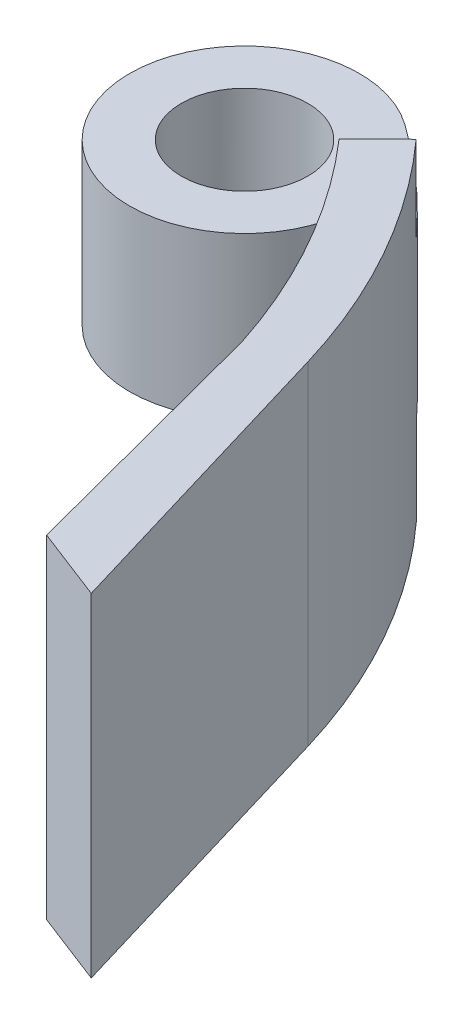
from build123d import *

# Parameters (mm, degrees)
SKETCH2_R                = 5.5
BOSS_EXTRUDE1_DEPTH      = 29
SKETCH3_R                = 12
CUT_EXTRUDE5_DEPTH       = 7
CUT_EXTRUDE5_DEPTH_BACK  = 0.5
SKETCH6_R                = 12
CUT_EXTRUDE6_DEPTH       = 7
CUT_EXTRUDE6_DEPTH_BACK  = 0.5
SKETCH9_R                = 4
SKETCH9_R_2              = 2
BOSS_EXTRUDE2_DEPTH      = 1
BOSS_EXTRUDE2_DEPTH_BACK = 1


with BuildPart() as part:
    # Sketch2 → Boss-Extrude1 (new body)
    with BuildSketch(Plane(origin=(0, 0, 0), x_dir=(1, 0, 0), z_dir=(0, 1, 0))):
        with BuildLine():
            ThreePointArc((50.009794046, 41.311227393), (41.887297641, 57.884223181), (28.818508763, 70.916716976))
            ThreePointArc((28.818508763, 70.916716976), (13.814285335, 58.864855467), (32.908133208, 61.2729792))
            ThreePointArc((32.908133208, 61.2729792), (40.45496434, 51.34849017), (45.618872448, 40.00017771))
            Line((45.618872448, 40.00017771), (51.710808427, 16.848599978))
            Line((51.710808427, 16.848599978), (58.045348615, 14.398829975))
            Line((58.045348615, 14.398829975), (50.009794046, 41.311227393))
        make_face()
        with Locations((23.020672213, 62.769012309)):
            Circle(SKETCH2_R, mode=Mode.SUBTRACT)
    extrude(amount=BOSS_EXTRUDE1_DEPTH)

    # Sketch3 → Cut-Extrude5 (cut, two sides)
    with BuildSketch(Plane(origin=(0, 7, 0), x_dir=(-1, 0, 0), z_dir=(0, -1, 0))) as cut_extrude5_sk:
        Polygon((-39.457331724, 64.63900974), (-16.53662743, 40.953334568), (-1.019451578, 59.252301049), (-23.940155872, 82.937976221), align=None)
        with Locations((-23.020672213, 62.769012309)):
            Circle(SKETCH3_R, mode=Mode.SUBTRACT)
        with BuildLine():
            ThreePointArc((-11.020672213, 62.769012309), (-24.609375035, 74.663381706), (-34.600009437, 59.619575938))
            Line((-34.600009437, 59.619575938), (-26.548423191, 51.29927068))
            ThreePointArc((-26.548423191, 51.29927068), (-15.890911057, 53.116732482), (-11.020672213, 62.769012309))
        make_face()
        with BuildLine():
            Line((-26.548423191, 51.29927068), (-34.600009437, 59.619575938))
            ThreePointArc((-34.600009437, 59.619575938), (-31.644064723, 54.424127551), (-26.548423191, 51.29927068))
        make_face()
    extrude(amount=CUT_EXTRUDE5_DEPTH, mode=Mode.SUBTRACT)
    extrude(cut_extrude5_sk.sketch, amount=-CUT_EXTRUDE5_DEPTH_BACK, mode=Mode.SUBTRACT)

    # Sketch6 → Cut-Extrude6 (cut, two sides)
    with BuildSketch(Plane(origin=(0, 22, 0), x_dir=(1, 0, 0), z_dir=(0, 1, 0))) as cut_extrude6_sk:
        Polygon((38.61882347, 63.432982973), (15.193844621, 40.271001155), (3.602276136, 63.900303012), (27.027254985, 87.06228483), align=None)
        with Locations((23.020672213, 62.769012309)):
            Circle(SKETCH6_R, mode=Mode.SUBTRACT)
        with BuildLine():
            ThreePointArc((26.262238297, 51.21512771), (31.457917246, 54.235965008), (34.537222393, 59.397206866))
            Line((34.537222393, 59.397206866), (26.262238297, 51.21512771))
        make_face()
        with BuildLine():
            Line((26.262238297, 51.21512771), (34.537222393, 59.397206866))
            ThreePointArc((34.537222393, 59.397206866), (34.899194894, 61.065868475), (35.020672213, 62.769012309))
            ThreePointArc((35.020672213, 62.769012309), (13.457754431, 70.018191814), (26.262238297, 51.21512771))
        make_face()
    extrude(amount=CUT_EXTRUDE6_DEPTH, mode=Mode.SUBTRACT)
    extrude(cut_extrude6_sk.sketch, amount=-CUT_EXTRUDE6_DEPTH_BACK, mode=Mode.SUBTRACT)

    # Sketch9 → Boss-Extrude2 (add, two sides)
    with BuildSketch(Plane(origin=(0, 14.5, 0), x_dir=(1, 0, 0), z_dir=(0, 1, 0))) as boss_extrude2_sk:
        with Locations((48.688174425, 28.621117181)):
            Circle(SKETCH9_R)
        with Locations((48.688174425, 28.621117181)):
            Circle(SKETCH9_R_2, mode=Mode.SUBTRACT)
    extrude(amount=BOSS_EXTRUDE2_DEPTH)
    extrude(boss_extrude2_sk.sketch, amount=-BOSS_EXTRUDE2_DEPTH_BACK)


solid = part.part
